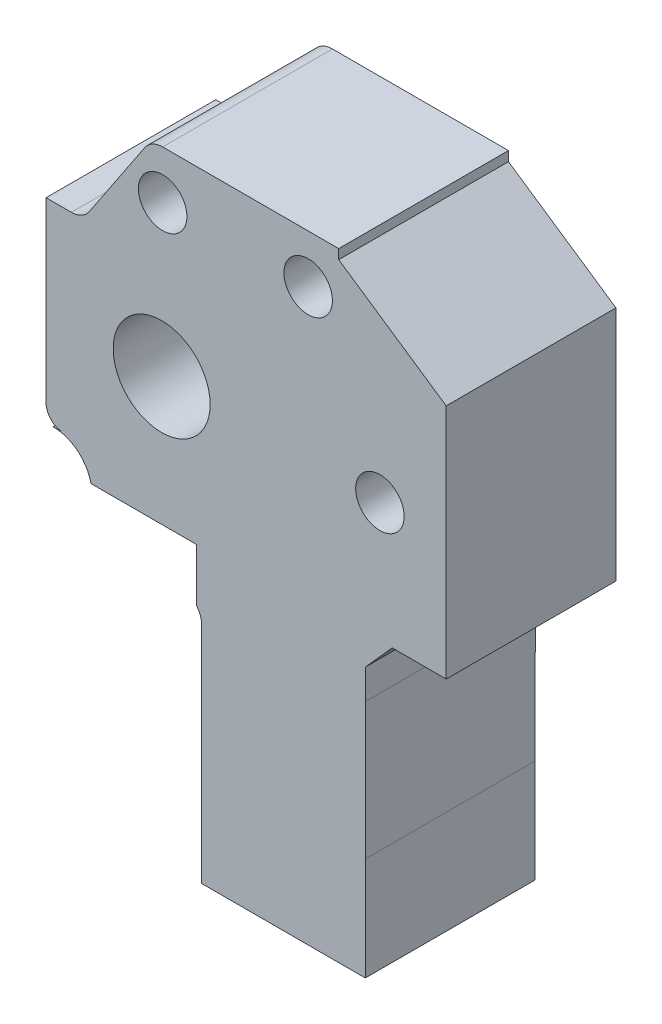
from build123d import *

# Parameters (mm, degrees)
SKETCH2_R           = 4
SKETCH2_R_2         = 2
BOSS_EXTRUDE1_DEPTH = 7


with BuildPart() as part:
    # Sketch2 → Boss-Extrude1 (new body, symmetric)
    with BuildSketch(Plane.XY):
        with BuildLine():
            Line((-6.131872753, 29.88679476), (5.868127247, 29.88679476))
            Line((5.868127247, 29.88679476), (7.594498309, 29.88679476))
            Line((7.594498309, 29.88679476), (8.387086053, 29.88679476))
            Line((8.387086053, 29.88679476), (8.387086053, 29.094207016))
            Line((8.387086053, 29.094207016), (17.251890726, 23.08634601))
            Line((17.251890726, 23.08634601), (17.251890726, 20.138485624))
            Line((17.251890726, 20.138485624), (17.251890726, 4.758566897))
            Line((17.251890726, 4.758566897), (17.251890726, 3.572124473))
            Line((17.251890726, 3.572124473), (12.798407994, 3.572124473))
            Line((12.798407994, 3.572124473), (10.603625269, 1.11753322))
            Line((10.603625269, 1.11753322), (10.603625269, -1.34605728))
            Line((10.603625269, -1.34605728), (10.581729624, -12.61320524))
            Line((10.581729624, -12.61320524), (10.581729624, -21.11320524))
            Line((10.581729624, -21.11320524), (-2.916105285, -21.11320524))
            Line((-2.916105285, -21.11320524), (-2.916105285, -12.61320524))
            Line((-2.916105285, -12.61320524), (-2.916105285, -2.61320524))
            ThreePointArc((-2.916105285, -2.61320524), (-3.030865934, -1.996216384), (-3.359797705, -1.461754837))
            Line((-3.359797705, -1.461754837), (-3.359797705, 2.88679476))
            Line((-3.359797705, 2.88679476), (-12.040045413, 2.88679476))
            ThreePointArc((-12.040045413, 2.88679476), (-13.161439875, 4.684724171), (-15.160732898, 5.38679476))
            Line((-15.160732898, 5.38679476), (-14.332399999, 5.38679476))
            ThreePointArc((-14.332399999, 5.38679476), (-15.333457628, 5.801446406), (-15.748109274, 6.802504035))
            Line((-15.748109274, 6.802504035), (-15.748109274, 20.089109399))
            Line((-15.748109274, 20.089109399), (-15.748109274, 21.453992916))
            Line((-15.748109274, 21.453992916), (-13.659474375, 21.453992916))
            ThreePointArc((-13.659474375, 21.453992916), (-12.819577694, 21.664599805), (-12.178425993, 22.246584507))
            Line((-12.178425993, 22.246584507), (-7.612913947, 29.094207016))
            ThreePointArc((-7.612913947, 29.094207016), (-6.971765358, 29.676188893), (-6.131872753, 29.88679476))
        make_face()
        with Locations((-6.213784577, 13.445806717)):
            Circle(SKETCH2_R, mode=Mode.SUBTRACT)
        with Locations((11.786215423, 13.445806717)):
            Circle(SKETCH2_R_2, mode=Mode.SUBTRACT)
        with Locations((-6.131872753, 25.90633221)):
            Circle(SKETCH2_R_2, mode=Mode.SUBTRACT)
        with Locations((5.868127247, 25.90633221)):
            Circle(SKETCH2_R_2, mode=Mode.SUBTRACT)
    extrude(amount=BOSS_EXTRUDE1_DEPTH, both=True)


solid = part.part
